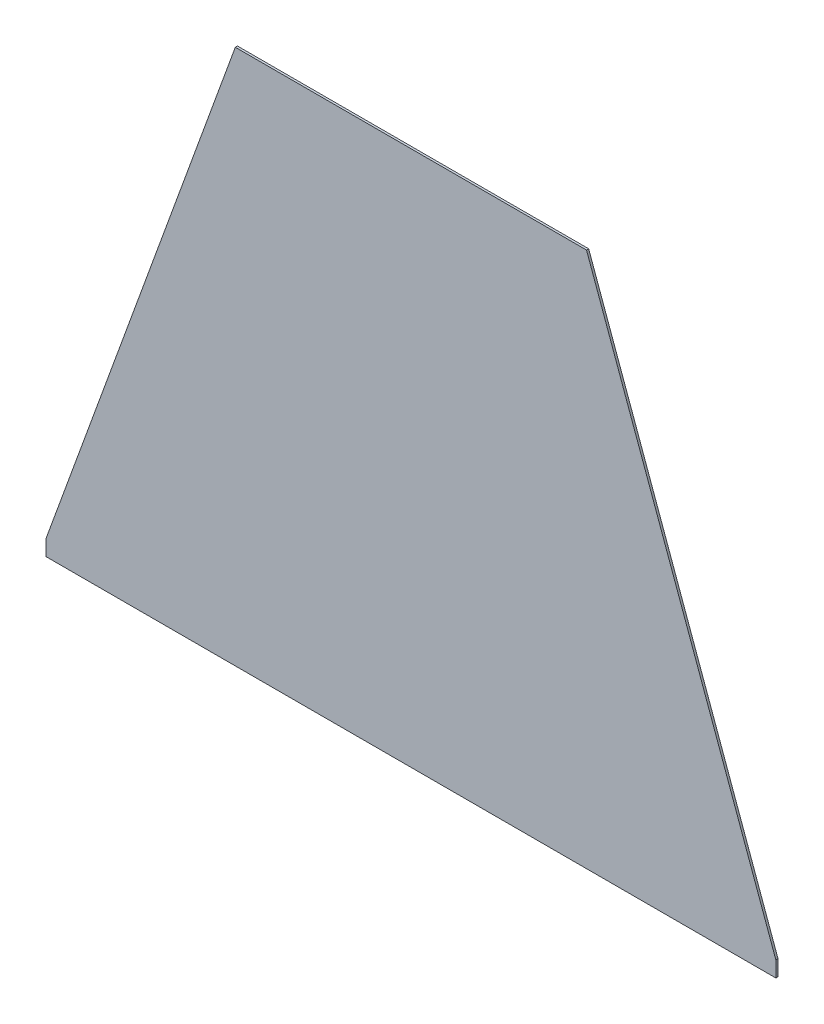
from build123d import *

# Parameters (mm, degrees)
SALIENTE_EXTRUIR1_DEPTH = 1.9
CROQUIS2_W              = 5
CROQUIS2_H              = 30.827719102
CROQUIS2_H_2            = 21.572663196
CORTAR_EXTRUIR1_DEPTH   = 10


with BuildPart() as part:
    # Croquis1 → Saliente-Extruir1 (new body)
    with BuildSketch(Plane.XY):
        Polygon((0, 0), (650, 0), (478.989928337, 469.846310393), (171.010071663, 469.846310393), align=None)
    extrude(amount=SALIENTE_EXTRUIR1_DEPTH)

    # Croquis2 → Cortar-Extruir1 (cut)
    with BuildSketch(Plane.XY.offset(1.9)):
        with Locations((647.5, 15.413859551)):
            Rectangle(CROQUIS2_W, CROQUIS2_H)
        with Locations((2.5, 10.786331598)):
            Rectangle(CROQUIS2_W, CROQUIS2_H_2)
    extrude(amount=-CORTAR_EXTRUIR1_DEPTH, mode=Mode.SUBTRACT)


solid = part.part
